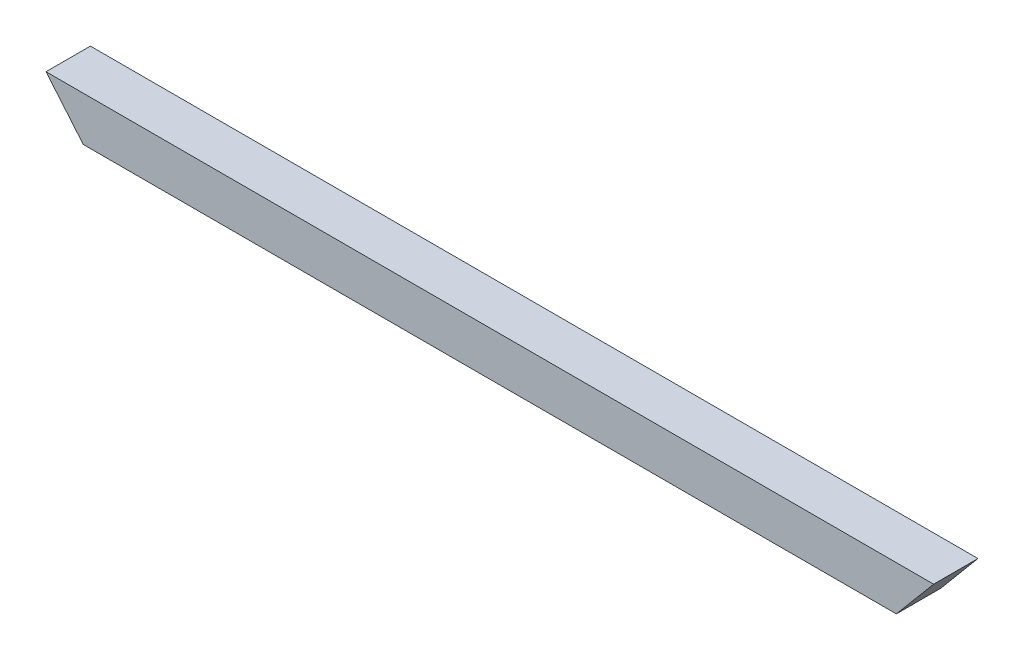
from build123d import *

# Parameters (mm, degrees)
BOSS_EXTRUDE1_DEPTH = 38.1


with BuildPart() as part:
    # Sketch1 → Boss-Extrude1 (new body)
    with BuildSketch(Plane(origin=(0, 0, 0), x_dir=(1, 0, 0), z_dir=(0, 0, -1))):
        Polygon((-31.969695948, -38.1), (0, 0), (698.060608104, 0), (730.030304052, -38.1), align=None)
    extrude(amount=BOSS_EXTRUDE1_DEPTH)


solid = part.part
